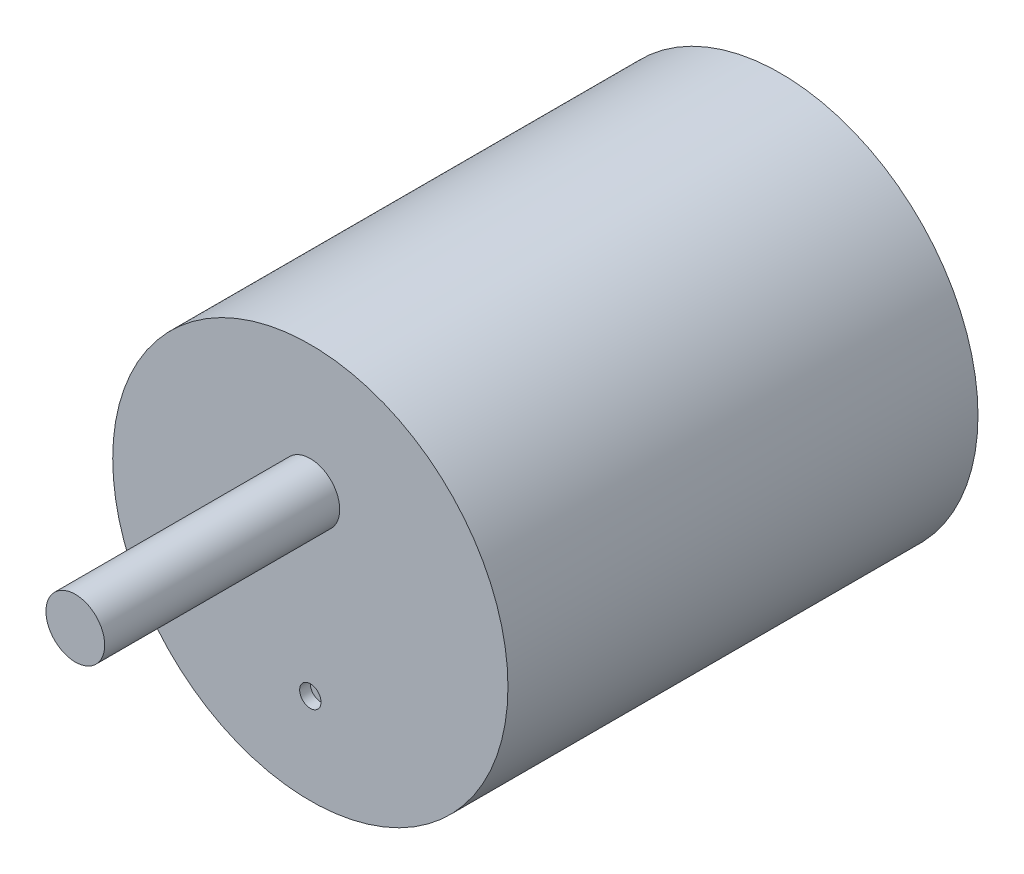
from build123d import *

# Parameters (mm, degrees)
SKETCH_1_R          = 18.5
EXTRUDE_1_DEPTH     = 44
SKETCH_2_R          = 2.75
EXTRUDE_2_DEPTH     = 22
SKETCH_3_R          = 1
CUT_EXTRUDE_1_DEPTH = 1


with BuildPart() as part:
    # 草图1 → 凸台-拉伸1 (new body)
    with BuildSketch(Plane.XY):
        Circle(SKETCH_1_R)
    extrude(amount=EXTRUDE_1_DEPTH)

    # 草图2 → 凸台-拉伸2 (add)
    with BuildSketch(Plane.XY.offset(44)):
        with Locations((0, 6.5)):
            Circle(SKETCH_2_R)
    extrude(amount=EXTRUDE_2_DEPTH)

    # 草图3 → 切除-拉伸1 (cut)
    with BuildSketch(Plane.XY.offset(44)):
        with Locations((0, -10)):
            Circle(SKETCH_3_R)
    extrude(amount=-CUT_EXTRUDE_1_DEPTH, mode=Mode.SUBTRACT)


solid = part.part
